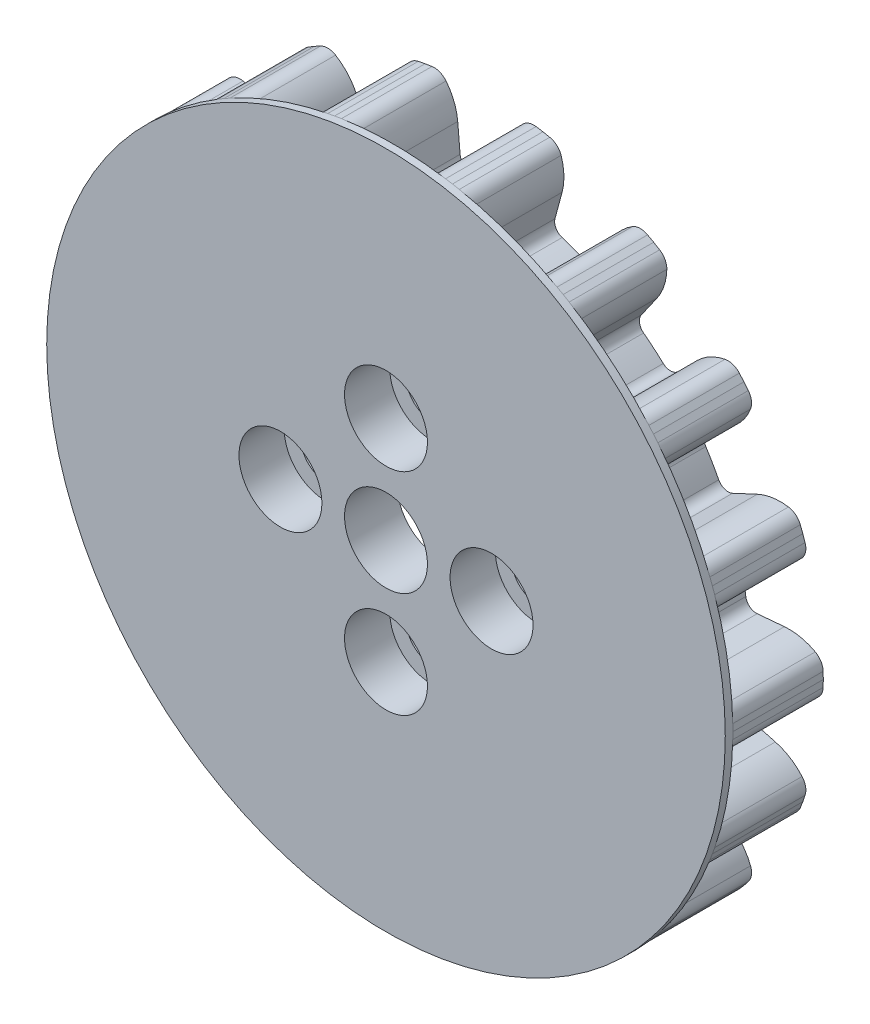
from build123d import *

# Parameters (mm, degrees)
BOSS_EXTRU_4_DEPTH           = 6
CONG_1_R                     = 0.7
CONG_2_R                     = 1
R_P_TITION_CIRCULAIRE1_COUNT = 18
ESQUISSE8_R                  = 22.5
BOSS_EXTRU_5_DEPTH           = 0.5
ESQUISSE9_R                  = 10.5
ENL_V_MAT_EXTRU_1_DEPTH      = 3
ENL_V_MAT_EXTRU_2_REACH      = 34.012
ESQUISSE10_R                 = 2.75
ESQUISSE10_R_2               = 1.65
ESQUISSE11_R                 = 2.75
ENL_V_MAT_EXTRU_3_DEPTH      = 3


with BuildPart() as part:
    # Esquisse4 → Boss.-Extru.4 (new body)
    with BuildSketch(Plane.XY):
        with BuildLine():
            ThreePointArc((17.433407217, -1.525225498), (17.350285074, -2.284208364), (17.234135678, -3.038843109))
            Line((17.234135678, -3.038843109), (0, 0))
            Line((0, 0), (17.234135678, 3.038843109))
            ThreePointArc((17.234135678, 3.038843109), (17.350285074, 2.284208364), (17.433407217, 1.525225498))
            Line((17.433407217, 1.525225498), (19.923893962, 1.743114855))
            ThreePointArc((19.923893962, 1.743114855), (21.273894998, 1.605964155), (22.478584986, 0.981436216))
            Line((22.478584986, 0.981436216), (22.5, 0))
            Line((22.5, 0), (22.478584986, -0.981436216))
            ThreePointArc((22.478584986, -0.981436216), (21.273894998, -1.605964155), (19.923893962, -1.743114855))
            Line((19.923893962, -1.743114855), (17.433407217, -1.525225498))
        make_face()
    extrude(amount=BOSS_EXTRU_4_DEPTH)

    # Congé1
    cong_1_edges = [part.edges().sort_by_distance(p)[0] for p in [
        (17.433407217, 1.525225498, 3),
        (17.433407217, -1.525225498, 3),
    ]]
    fillet(cong_1_edges, radius=CONG_1_R)

    # Congé2
    cong_2_edges = [part.edges().sort_by_distance(p)[0] for p in [
        (22.478584986, 0.981436216, 3),
        (22.478584986, -0.981436216, 3),
    ]]
    fillet(cong_2_edges, radius=CONG_2_R)


with BuildPart() as r_p_tition_circulaire1_1:
    # Répétition circulaire1: pattern copy
    add(part.part.rotate(Axis((0, 0, 0), (0, 0, 1)), 1 * 360 / R_P_TITION_CIRCULAIRE1_COUNT))


with BuildPart() as r_p_tition_circulaire1_2:
    # Répétition circulaire1: pattern copy
    add(part.part.rotate(Axis((0, 0, 0), (0, 0, 1)), 2 * 360 / R_P_TITION_CIRCULAIRE1_COUNT))


with BuildPart() as r_p_tition_circulaire1_3:
    # Répétition circulaire1: pattern copy
    add(part.part.rotate(Axis((0, 0, 0), (0, 0, 1)), 3 * 360 / R_P_TITION_CIRCULAIRE1_COUNT))


with BuildPart() as r_p_tition_circulaire1_4:
    # Répétition circulaire1: pattern copy
    add(part.part.rotate(Axis((0, 0, 0), (0, 0, 1)), 4 * 360 / R_P_TITION_CIRCULAIRE1_COUNT))


with BuildPart() as r_p_tition_circulaire1_5:
    # Répétition circulaire1: pattern copy
    add(part.part.rotate(Axis((0, 0, 0), (0, 0, 1)), 5 * 360 / R_P_TITION_CIRCULAIRE1_COUNT))


with BuildPart() as r_p_tition_circulaire1_6:
    # Répétition circulaire1: pattern copy
    add(part.part.rotate(Axis((0, 0, 0), (0, 0, 1)), 6 * 360 / R_P_TITION_CIRCULAIRE1_COUNT))


with BuildPart() as r_p_tition_circulaire1_7:
    # Répétition circulaire1: pattern copy
    add(part.part.rotate(Axis((0, 0, 0), (0, 0, 1)), 7 * 360 / R_P_TITION_CIRCULAIRE1_COUNT))


with BuildPart() as r_p_tition_circulaire1_8:
    # Répétition circulaire1: pattern copy
    add(part.part.rotate(Axis((0, 0, 0), (0, 0, 1)), 8 * 360 / R_P_TITION_CIRCULAIRE1_COUNT))


with BuildPart() as r_p_tition_circulaire1_9:
    # Répétition circulaire1: pattern copy
    add(part.part.rotate(Axis((0, 0, 0), (0, 0, 1)), 9 * 360 / R_P_TITION_CIRCULAIRE1_COUNT))


with BuildPart() as r_p_tition_circulaire1_10:
    # Répétition circulaire1: pattern copy
    add(part.part.rotate(Axis((0, 0, 0), (0, 0, 1)), 10 * 360 / R_P_TITION_CIRCULAIRE1_COUNT))


with BuildPart() as r_p_tition_circulaire1_11:
    # Répétition circulaire1: pattern copy
    add(part.part.rotate(Axis((0, 0, 0), (0, 0, 1)), 11 * 360 / R_P_TITION_CIRCULAIRE1_COUNT))


with BuildPart() as r_p_tition_circulaire1_12:
    # Répétition circulaire1: pattern copy
    add(part.part.rotate(Axis((0, 0, 0), (0, 0, 1)), 12 * 360 / R_P_TITION_CIRCULAIRE1_COUNT))


with BuildPart() as r_p_tition_circulaire1_13:
    # Répétition circulaire1: pattern copy
    add(part.part.rotate(Axis((0, 0, 0), (0, 0, 1)), 13 * 360 / R_P_TITION_CIRCULAIRE1_COUNT))


with BuildPart() as r_p_tition_circulaire1_14:
    # Répétition circulaire1: pattern copy
    add(part.part.rotate(Axis((0, 0, 0), (0, 0, 1)), 14 * 360 / R_P_TITION_CIRCULAIRE1_COUNT))


with BuildPart() as r_p_tition_circulaire1_15:
    # Répétition circulaire1: pattern copy
    add(part.part.rotate(Axis((0, 0, 0), (0, 0, 1)), 15 * 360 / R_P_TITION_CIRCULAIRE1_COUNT))


with BuildPart() as r_p_tition_circulaire1_16:
    # Répétition circulaire1: pattern copy
    add(part.part.rotate(Axis((0, 0, 0), (0, 0, 1)), 16 * 360 / R_P_TITION_CIRCULAIRE1_COUNT))


with BuildPart() as r_p_tition_circulaire1_17:
    # Répétition circulaire1: pattern copy
    add(part.part.rotate(Axis((0, 0, 0), (0, 0, 1)), 17 * 360 / R_P_TITION_CIRCULAIRE1_COUNT))


with BuildPart() as part_1:
    add(part.part)

    add(r_p_tition_circulaire1_1.part)  # Boss.-Extru.5 merges Répétition circulaire1_1

    add(r_p_tition_circulaire1_2.part)  # Boss.-Extru.5 merges Répétition circulaire1_2

    add(r_p_tition_circulaire1_3.part)  # Boss.-Extru.5 merges Répétition circulaire1_3

    add(r_p_tition_circulaire1_4.part)  # Boss.-Extru.5 merges Répétition circulaire1_4

    add(r_p_tition_circulaire1_5.part)  # Boss.-Extru.5 merges Répétition circulaire1_5

    add(r_p_tition_circulaire1_6.part)  # Boss.-Extru.5 merges Répétition circulaire1_6

    add(r_p_tition_circulaire1_7.part)  # Boss.-Extru.5 merges Répétition circulaire1_7

    add(r_p_tition_circulaire1_8.part)  # Boss.-Extru.5 merges Répétition circulaire1_8

    add(r_p_tition_circulaire1_9.part)  # Boss.-Extru.5 merges Répétition circulaire1_9

    add(r_p_tition_circulaire1_10.part)  # Boss.-Extru.5 merges Répétition circulaire1_10

    add(r_p_tition_circulaire1_11.part)  # Boss.-Extru.5 merges Répétition circulaire1_11

    add(r_p_tition_circulaire1_12.part)  # Boss.-Extru.5 merges Répétition circulaire1_12

    add(r_p_tition_circulaire1_13.part)  # Boss.-Extru.5 merges Répétition circulaire1_13

    add(r_p_tition_circulaire1_14.part)  # Boss.-Extru.5 merges Répétition circulaire1_14

    add(r_p_tition_circulaire1_15.part)  # Boss.-Extru.5 merges Répétition circulaire1_15

    add(r_p_tition_circulaire1_16.part)  # Boss.-Extru.5 merges Répétition circulaire1_16

    add(r_p_tition_circulaire1_17.part)  # Boss.-Extru.5 merges Répétition circulaire1_17
    # Esquisse8 → Boss.-Extru.5 (add)
    with BuildSketch(Plane.XY.offset(6)):
        Circle(ESQUISSE8_R)
    extrude(amount=BOSS_EXTRU_5_DEPTH)

    # Esquisse9 → Enlèv. mat.-Extru.1 (cut)
    with BuildSketch(Plane(origin=(0, 0, 0), x_dir=(-1, 0, 0), z_dir=(0, 0, -1))):
        Circle(ESQUISSE9_R)
    extrude(amount=-ENL_V_MAT_EXTRU_1_DEPTH, mode=Mode.SUBTRACT)

    # Esquisse10 → Enlèv. mat.-Extru.2 (cut, up to next)
    with BuildSketch(Plane(origin=(0, 0, 3), x_dir=(-1, 0, 0), z_dir=(0, 0, -1)), mode=Mode.PRIVATE) as enl_v_mat_extru_2_sk1:
        Circle(ESQUISSE10_R)
    enl_v_mat_extru_2_tool1 = extrude(enl_v_mat_extru_2_sk1.sketch, amount=-ENL_V_MAT_EXTRU_2_REACH, mode=Mode.PRIVATE) & part_1.part
    # Esquisse10 → Enlèv. mat.-Extru.2 (cut, up to next)
    with BuildSketch(Plane(origin=(0, 0, 3), x_dir=(-1, 0, 0), z_dir=(0, 0, -1)), mode=Mode.PRIVATE) as enl_v_mat_extru_2_sk2:
        with Locations((0, 7)):
            Circle(ESQUISSE10_R_2)
    enl_v_mat_extru_2_tool2 = extrude(enl_v_mat_extru_2_sk2.sketch, amount=-ENL_V_MAT_EXTRU_2_REACH, mode=Mode.PRIVATE) & part_1.part
    # Esquisse10 → Enlèv. mat.-Extru.2 (cut, up to next)
    with BuildSketch(Plane(origin=(0, 0, 3), x_dir=(-1, 0, 0), z_dir=(0, 0, -1)), mode=Mode.PRIVATE) as enl_v_mat_extru_2_sk3:
        with Locations((7, 0)):
            Circle(ESQUISSE10_R_2)
    enl_v_mat_extru_2_tool3 = extrude(enl_v_mat_extru_2_sk3.sketch, amount=-ENL_V_MAT_EXTRU_2_REACH, mode=Mode.PRIVATE) & part_1.part
    # Esquisse10 → Enlèv. mat.-Extru.2 (cut, up to next)
    with BuildSketch(Plane(origin=(0, 0, 3), x_dir=(-1, 0, 0), z_dir=(0, 0, -1)), mode=Mode.PRIVATE) as enl_v_mat_extru_2_sk4:
        with Locations((0, -7)):
            Circle(ESQUISSE10_R_2)
    enl_v_mat_extru_2_tool4 = extrude(enl_v_mat_extru_2_sk4.sketch, amount=-ENL_V_MAT_EXTRU_2_REACH, mode=Mode.PRIVATE) & part_1.part
    # Esquisse10 → Enlèv. mat.-Extru.2 (cut, up to next)
    with BuildSketch(Plane(origin=(0, 0, 3), x_dir=(-1, 0, 0), z_dir=(0, 0, -1)), mode=Mode.PRIVATE) as enl_v_mat_extru_2_sk5:
        with Locations((-7, 0)):
            Circle(ESQUISSE10_R_2)
    enl_v_mat_extru_2_tool5 = extrude(enl_v_mat_extru_2_sk5.sketch, amount=-ENL_V_MAT_EXTRU_2_REACH, mode=Mode.PRIVATE) & part_1.part
    add(enl_v_mat_extru_2_tool1.solids().sort_by_distance((0, 0, 3))[0], mode=Mode.SUBTRACT)
    add(enl_v_mat_extru_2_tool2.solids().sort_by_distance((0, 7, 3))[0], mode=Mode.SUBTRACT)
    add(enl_v_mat_extru_2_tool3.solids().sort_by_distance((-7, 0, 3))[0], mode=Mode.SUBTRACT)
    add(enl_v_mat_extru_2_tool4.solids().sort_by_distance((0, -7, 3))[0], mode=Mode.SUBTRACT)
    add(enl_v_mat_extru_2_tool5.solids().sort_by_distance((7, 0, 3))[0], mode=Mode.SUBTRACT)

    # Esquisse11 → Enlèv. mat.-Extru.3 (cut)
    with BuildSketch(Plane.XY.offset(6.5)):
        with Locations((0, 7)):
            Circle(ESQUISSE11_R)
        with Locations((7, 0)):
            Circle(ESQUISSE11_R)
        with Locations((0, -7)):
            Circle(ESQUISSE11_R)
        with Locations((-7, 0)):
            Circle(ESQUISSE11_R)
    extrude(amount=-ENL_V_MAT_EXTRU_3_DEPTH, mode=Mode.SUBTRACT)


solid = part_1.part
